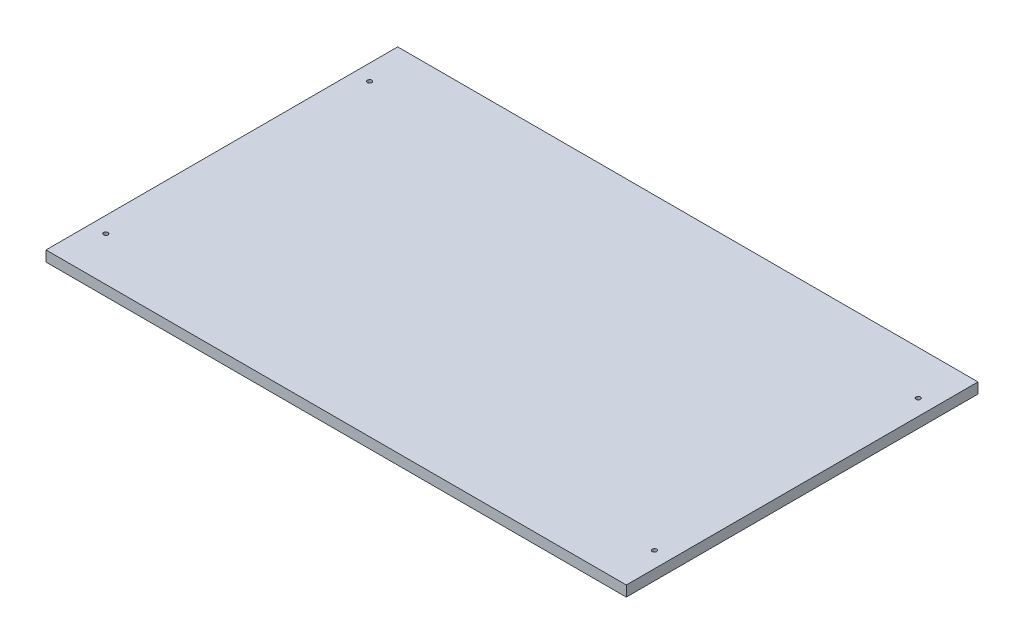
from build123d import *

# Parameters (mm, degrees)
SKETCH1_W           = 330
SKETCH1_H           = 200
BOSS_EXTRUDE1_DEPTH = 6
SKETCH4_R           = 1.25
CUT_EXTRUDE1_DEPTH  = 7


with BuildPart() as part:
    # Sketch1 → Boss-Extrude1 (new body)
    with BuildSketch(Plane(origin=(0, 0, 0), x_dir=(1, 0, 0), z_dir=(0, 1, 0))):
        with Locations((165, 100)):
            Rectangle(SKETCH1_W, SKETCH1_H)
    extrude(amount=BOSS_EXTRUDE1_DEPTH)

    # Sketch4 → Cut-Extrude1 (cut, through all)
    with BuildSketch(Plane.XZ):
        with Locations((9, -175)):
            Circle(SKETCH4_R)
        with Locations((9, -25)):
            Circle(SKETCH4_R)
        with Locations((321, -175)):
            Circle(SKETCH4_R)
        with Locations((321, -25)):
            Circle(SKETCH4_R)
    extrude(amount=-CUT_EXTRUDE1_DEPTH, mode=Mode.SUBTRACT)


solid = part.part
